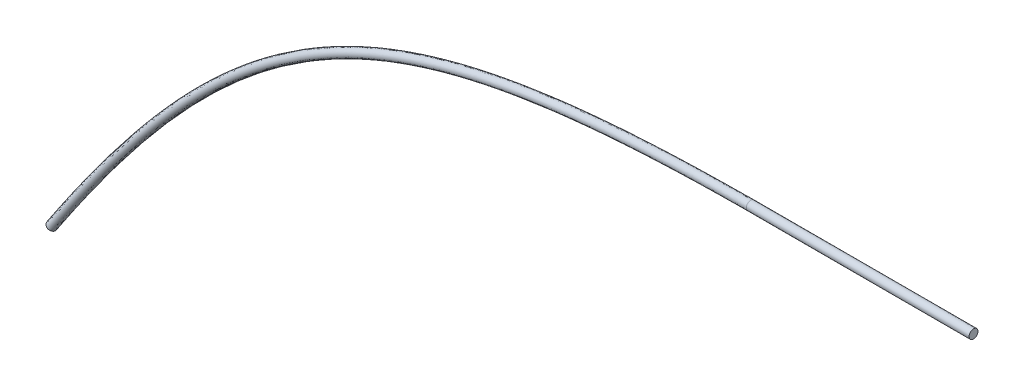
from build123d import *

# Parameters (mm, degrees)
SKETCH1_R      = 0.254
EXTRUDE1_DEPTH = 12.7
SKETCH3_R      = 0.254


with BuildPart() as part:
    # Sketch1 → Extrude1 (new body)
    with BuildSketch(Plane(origin=(8.378830045, 0.000415154, 0), x_dir=(0, 0, 1), z_dir=(-0.999999999, -4.9548e-05, 0))):
        with Locations((6.169114453, 30.84051151)):
            Circle(SKETCH1_R)
    extrude(amount=-EXTRUDE1_DEPTH)

    # Sweep1: sweep along a path in Sketch4
    with BuildLine(Plane.XY.offset(6.169114453)) as sweep1_path:
        add(Edge.make_bspline(
            [(8.377301959, 30.840926626), (-12.031583431, 30.714094307), (-20.148382532, 26.937476348), (-31.469136273, 9.913190036)],
            knots=[0, 0, 0, 0, 1, 1, 1, 1], degree=3))
    # Sketch3 → Sweep1 (sweep)
    with BuildSketch(Plane(origin=(8.378830045, 0.000415154, 0), x_dir=(0, 0, 1), z_dir=(-0.999999999, -4.9548e-05, 0))):
        with Locations((6.169114453, 30.84051151)):
            Circle(SKETCH3_R)
    sweep(path=sweep1_path.line)


solid = part.part
